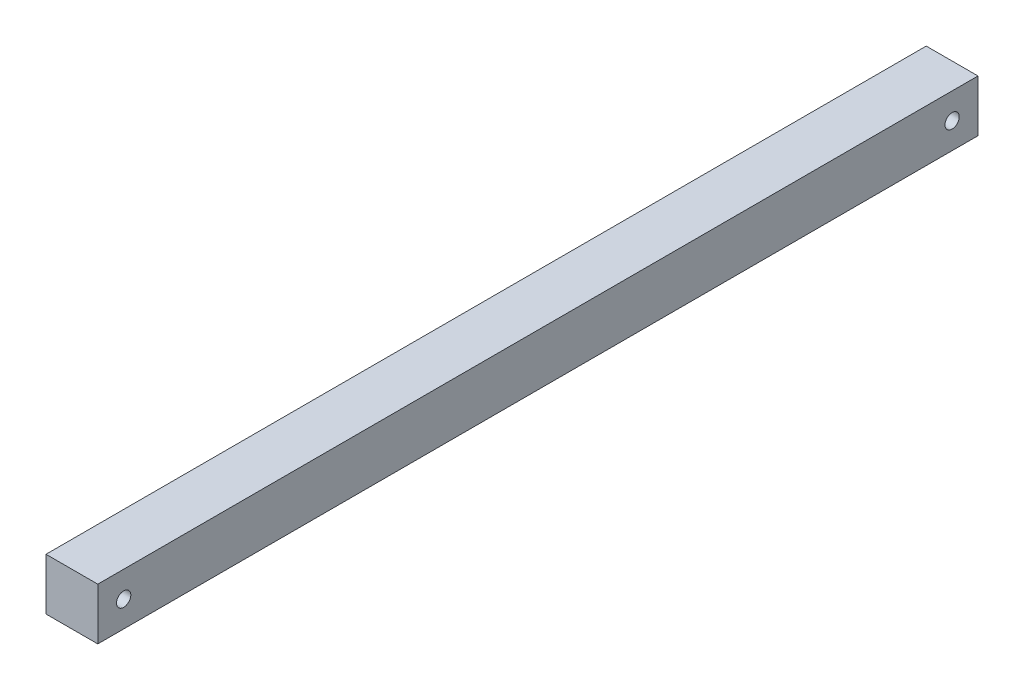
from build123d import *

# Parameters (mm, degrees)
SKETCH1_W           = 25.4
SKETCH1_H           = 25.4
BOSS_EXTRUDE1_DEPTH = 431.8
SKETCH10_R          = 3.5
CUT_EXTRUDE6_DEPTH  = 26.4


with BuildPart() as part:
    # Sketch1 → Boss-Extrude1 (new body)
    with BuildSketch(Plane.XY):
        Rectangle(SKETCH1_W, SKETCH1_H)
    extrude(amount=BOSS_EXTRUDE1_DEPTH)

    # Sketch10 → Cut-Extrude6 (cut, through all)
    with BuildSketch(Plane.ZY.offset(12.7)):
        with Locations((419.1, 0)):
            Circle(SKETCH10_R)
        with Locations((12.7, 0)):
            Circle(SKETCH10_R)
    extrude(amount=-CUT_EXTRUDE6_DEPTH, mode=Mode.SUBTRACT)


solid = part.part
